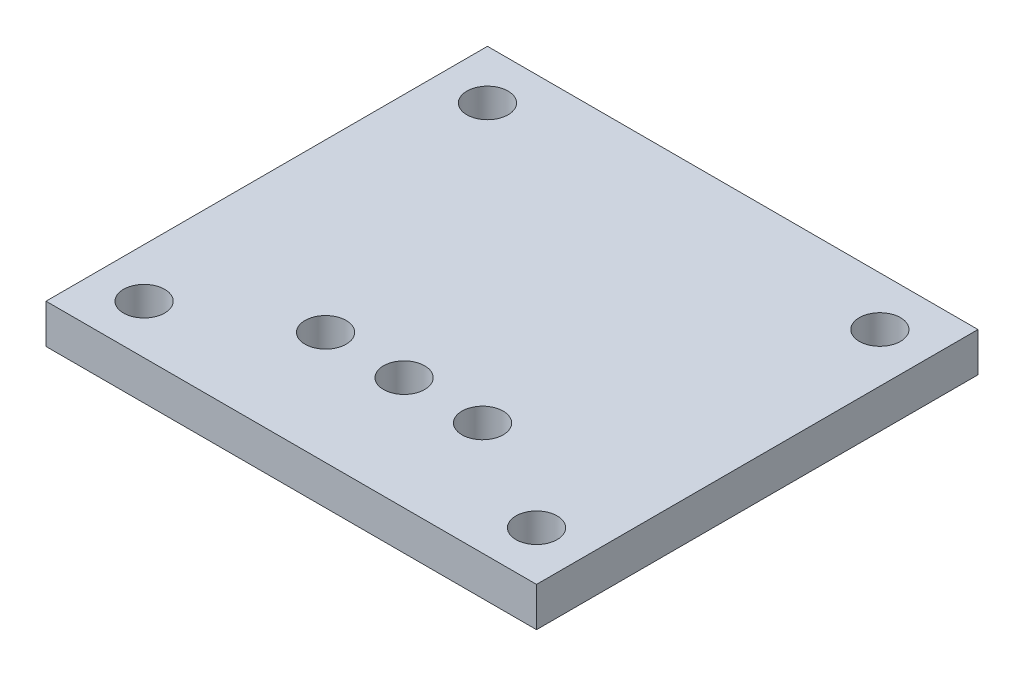
from build123d import *

# Parameters (mm, degrees)
SKETCH_1_W          = 50
SKETCH_1_H          = 45
EXTRUDE_1_DEPTH     = 4
SKETCH_2_R          = 2.1
CUT_EXTRUDE_1_DEPTH = 5
SKETCH_5_R          = 2.1
CUT_EXTRUDE_4_DEPTH = 5


with BuildPart() as part:
    # 草图1 → 凸台-拉伸1 (new body)
    with BuildSketch(Plane(origin=(0, 0, 0), x_dir=(1, 0, 0), z_dir=(0, 1, 0))):
        Rectangle(SKETCH_1_W, SKETCH_1_H)
    extrude(amount=EXTRUDE_1_DEPTH)

    # 草图2 → 切除-拉伸1 (cut, through all)
    with BuildSketch(Plane(origin=(0, 4, 0), x_dir=(1, 0, 0), z_dir=(0, 1, 0))):
        with Locations((0, -11)):
            Circle(SKETCH_2_R)
        with Locations((8, -11)):
            Circle(SKETCH_2_R)
        with Locations((-8, -11)):
            Circle(SKETCH_2_R)
    extrude(amount=-CUT_EXTRUDE_1_DEPTH, mode=Mode.SUBTRACT)

    # 草图5 → 切除-拉伸4 (cut, through all)
    with BuildSketch(Plane(origin=(0, 0, 0), x_dir=(-1, 0, 0), z_dir=(0, -1, 0))):
        with Locations((20, -17.5)):
            Circle(SKETCH_5_R)
        with Locations((20, 17.5)):
            Circle(SKETCH_5_R)
        with Locations((-20, 17.5)):
            Circle(SKETCH_5_R)
        with Locations((-20, -17.5)):
            Circle(SKETCH_5_R)
    extrude(amount=-CUT_EXTRUDE_4_DEPTH, mode=Mode.SUBTRACT)


solid = part.part
